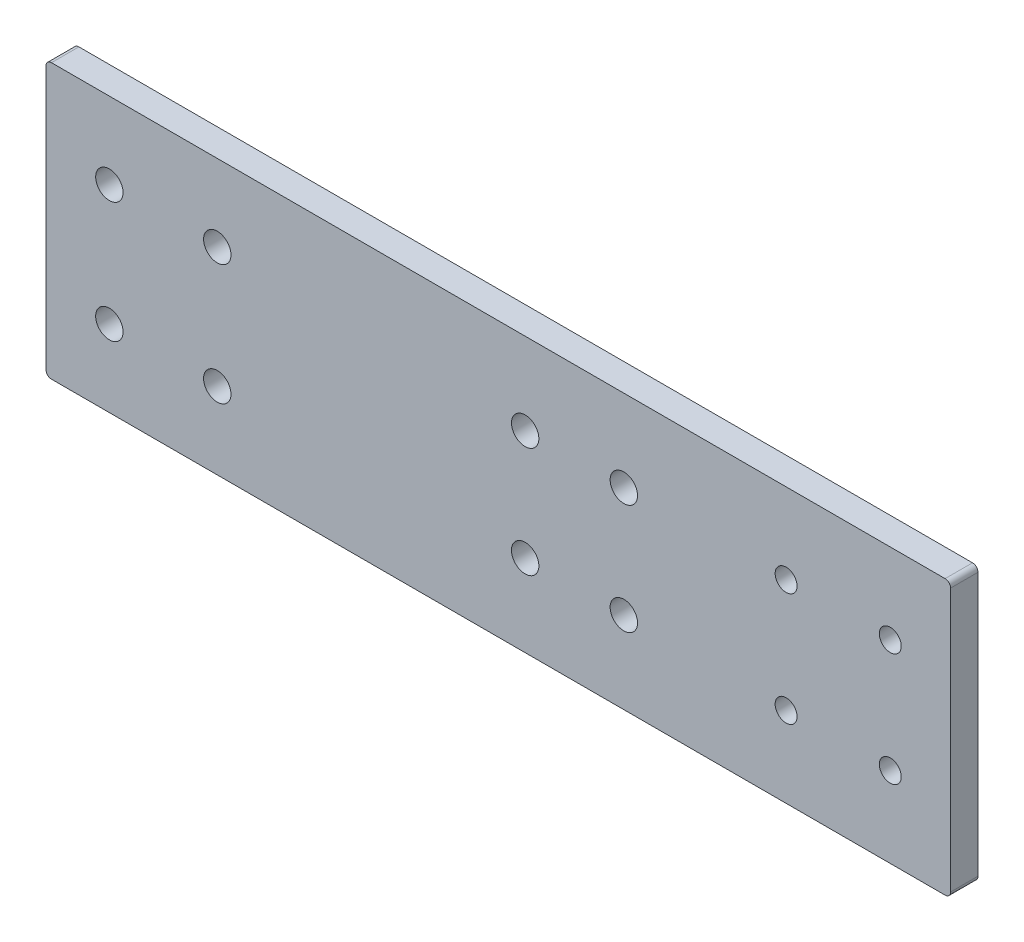
from build123d import *

# Parameters (mm, degrees)
SKETCH1_R           = 2
SKETCH1_R_2         = 2.5
BOSS_EXTRUDE1_DEPTH = 5


with BuildPart() as part:
    # Sketch1 → Boss-Extrude1 (new body)
    with BuildSketch(Plane.XY):
        with BuildLine():
            Line((1, 0), (164, 0))
            ThreePointArc((164, 0), (164.707106781, 0.292893219), (165, 1))
            Line((165, 1), (165, 49))
            ThreePointArc((165, 49), (164.707106781, 49.707106781), (164, 50))
            Line((164, 50), (1, 50))
            ThreePointArc((1, 50), (0.292893219, 49.707106781), (0, 49))
            Line((0, 49), (0, 1))
            ThreePointArc((0, 1), (0.292893219, 0.292893219), (1, 0))
        make_face()
        with Locations((135, 35.314285714)):
            Circle(SKETCH1_R, mode=Mode.SUBTRACT)
        with Locations((135, 14.685714286)):
            Circle(SKETCH1_R, mode=Mode.SUBTRACT)
        with Locations((154, 14.685714286)):
            Circle(SKETCH1_R, mode=Mode.SUBTRACT)
        with Locations((154, 35.314285714)):
            Circle(SKETCH1_R, mode=Mode.SUBTRACT)
        with Locations((105.4, 35.058823529)):
            Circle(SKETCH1_R_2, mode=Mode.SUBTRACT)
        with Locations((105.4, 14.941176471)):
            Circle(SKETCH1_R_2, mode=Mode.SUBTRACT)
        with Locations((87.4, 14.941176471)):
            Circle(SKETCH1_R_2, mode=Mode.SUBTRACT)
        with Locations((87.4, 35.058823529)):
            Circle(SKETCH1_R_2, mode=Mode.SUBTRACT)
        with Locations((11.557894737, 36)):
            Circle(SKETCH1_R_2, mode=Mode.SUBTRACT)
        with Locations((11.557894737, 14)):
            Circle(SKETCH1_R_2, mode=Mode.SUBTRACT)
        with Locations((31.242105263, 14)):
            Circle(SKETCH1_R_2, mode=Mode.SUBTRACT)
        with Locations((31.242105263, 36)):
            Circle(SKETCH1_R_2, mode=Mode.SUBTRACT)
    extrude(amount=BOSS_EXTRUDE1_DEPTH)


solid = part.part
